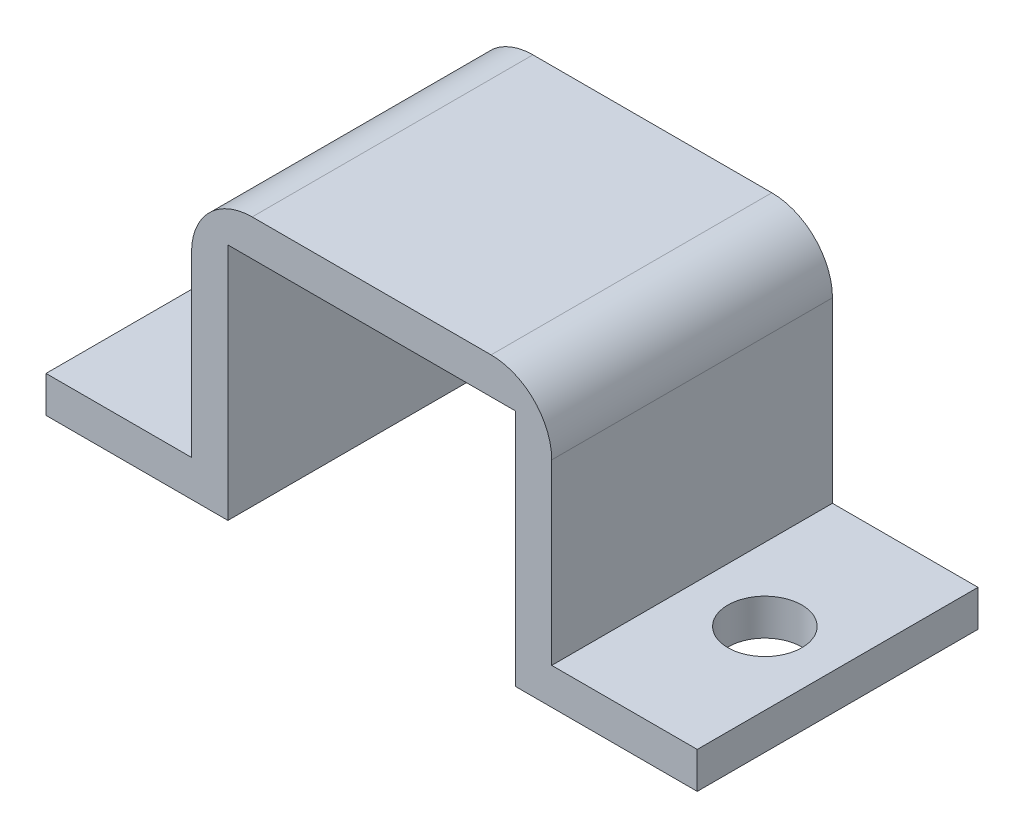
from build123d import *

# Parameters (mm, degrees)
BOSS_EXTRUDE1_DEPTH = 11.7602
FILLET2_R           = 2.54
FILLET3_R           = 2.54
SKETCH3_R           = 1.55
CUT_EXTRUDE1_DEPTH  = 1.524


with BuildPart() as part:
    # Sketch2 → Boss-Extrude1 (new body)
    with BuildSketch(Plane.XY):
        Polygon((0, 0), (7.62, 0), (7.62, 9.9949), (19.6596, 9.9949), (19.6596, 0), (27.2796, 0), (27.2796, 1.524), (21.1836, 1.524), (21.1836, 11.5189), (6.096, 11.5189), (6.096, 1.524), (0, 1.524), align=None)
    extrude(amount=BOSS_EXTRUDE1_DEPTH)

    # Fillet2
    fillet2_edges = [part.edges().sort_by_distance(p)[0] for p in [
        (21.1836, 11.5189, 5.8801),
    ]]
    fillet(fillet2_edges, radius=FILLET2_R)

    # Fillet3
    fillet3_edges = [part.edges().sort_by_distance(p)[0] for p in [
        (6.096, 11.5189, 5.8801),
    ]]
    fillet(fillet3_edges, radius=FILLET3_R)

    # Sketch3 → Cut-Extrude1 (cut)
    with BuildSketch(Plane(origin=(0, 0, 0), x_dir=(1, 0, 0), z_dir=(0, 1, 0))):
        with Locations((3.048, -5.8801)):
            Circle(SKETCH3_R)
        with Locations((24.2316, -5.8801)):
            Circle(SKETCH3_R)
    extrude(amount=CUT_EXTRUDE1_DEPTH, mode=Mode.SUBTRACT)


solid = part.part
